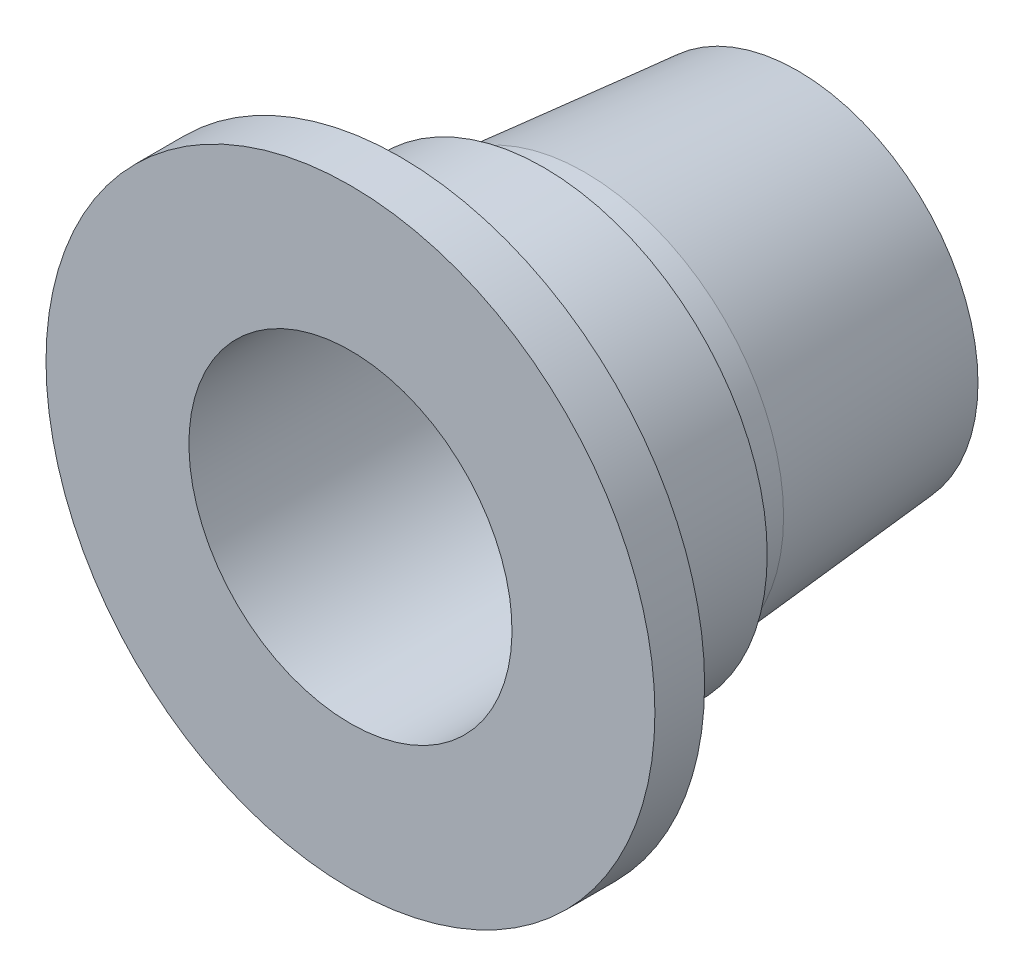
from build123d import *

# Parameters (mm, degrees)
CHAMFER_1_SIZE         = 0.8
CHAMFER_1_SIZE2        = 0.461880215
CHAMFER_1_PART_2_SIZE  = 0.8
CHAMFER_1_PART_2_SIZE2 = 0.461880215


with BuildPart() as part:
    # Эскиз1 → Повернуть1 (revolve)
    with BuildSketch(Plane(origin=(0, 0, 0), x_dir=(0, 0, -1), z_dir=(1, 0, 0))):
        Polygon((0, 13), (36, 13), (36, 14.5), (18.854921546, 16), (16, 16), (16, 18), (7, 18), (7, 16), (4, 16), (4, 24.5), (0, 24.5), align=None)
    revolve(axis=Axis((0, 0, 0), (0, 0, -1)))

    # Фаска1
    chamfer_1_edges = [part.edges().sort_by_distance(p)[0] for p in [
        (0, -18, -7),
    ]]
    chamfer_1_side = [part.faces().sort_by_distance(p)[0] for p in [
        (0, -17.490883118, -7),
    ]]
    chamfer(chamfer_1_edges, length=CHAMFER_1_SIZE, length2=CHAMFER_1_SIZE2, reference=chamfer_1_side[0])

    # Фаска1 part 2
    chamfer_1_part_2_edges = [part.edges().sort_by_distance(p)[0] for p in [
        (0, -18, -16),
    ]]
    chamfer_1_part_2_side = [part.faces().sort_by_distance(p)[0] for p in [
        (0, -16.509116882, -16),
    ]]
    chamfer(chamfer_1_part_2_edges, length=CHAMFER_1_PART_2_SIZE, length2=CHAMFER_1_PART_2_SIZE2, reference=chamfer_1_part_2_side[0])


solid = part.part
